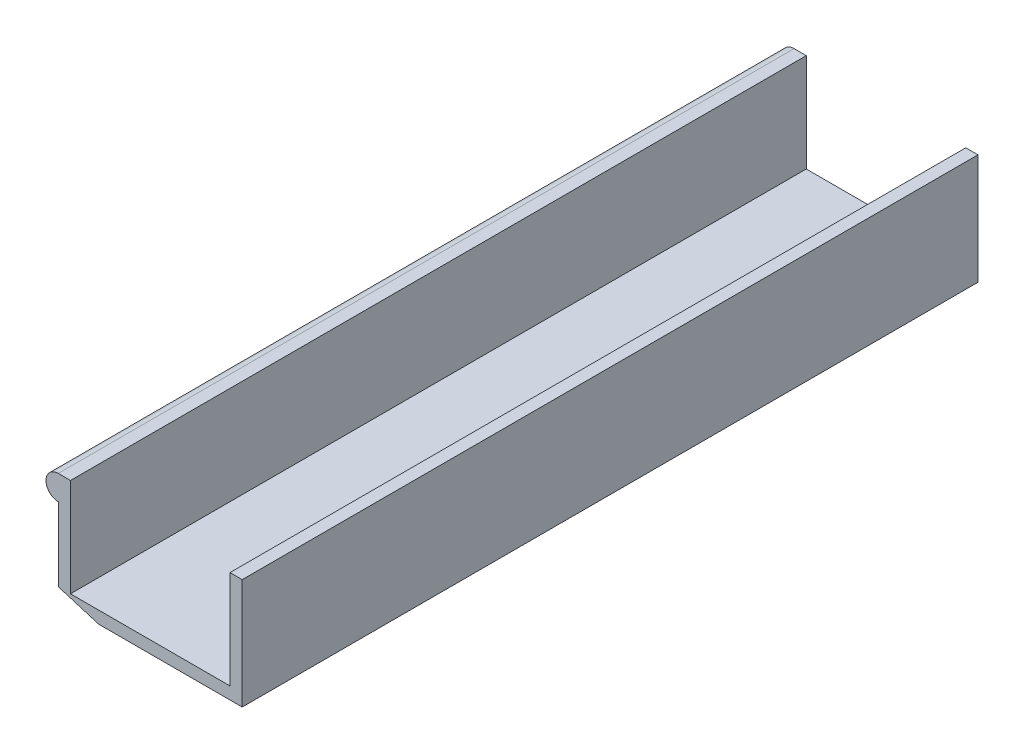
from build123d import *

# Parameters (mm, degrees)
EXTRUDE_1_DEPTH = 600


with BuildPart() as part:
    # 草圖1 → 填料-伸長1 (new body)
    with BuildSketch(Plane.XY):
        with BuildLine():
            Line((-111.245584272, 70), (-111.245584272, 10))
            Line((-111.245584272, 10), (-78.271679835, 0))
            Line((-78.271679835, 0), (38.754415728, 0))
            Line((38.754415728, 0), (38.754415728, 90))
            Line((38.754415728, 90), (28.803601488, 90))
            Line((28.803601488, 90), (28.803601488, 9.95081424))
            Line((28.803601488, 9.95081424), (-101.294770031, 9.95081424))
            Line((-101.294770031, 9.95081424), (-101.294770031, 90))
            Line((-101.294770031, 90), (-111.245584272, 90))
            ThreePointArc((-111.245584272, 90), (-121.245584272, 80), (-111.245584272, 70))
        make_face()
    extrude(amount=EXTRUDE_1_DEPTH)


solid = part.part
